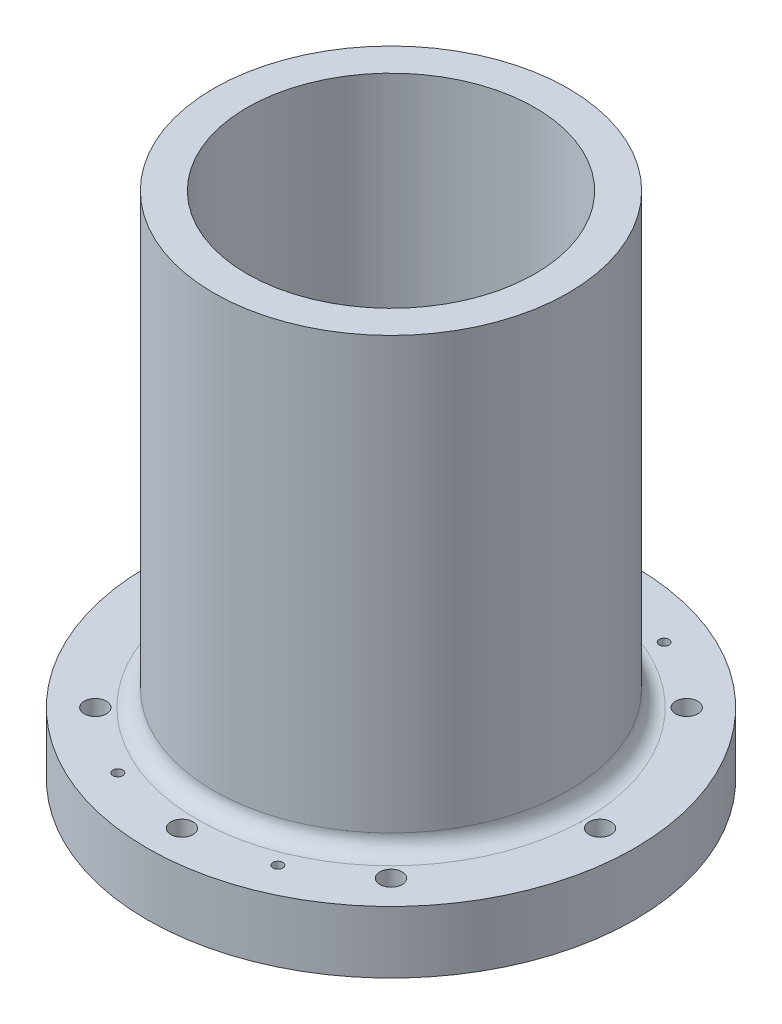
from build123d import *

# Parameters (mm, degrees)
SKETCH2_R               = 50.8
SKETCH2_R_2             = 41.275
BASE_CYLINDER_DEPTH     = 292.1
SKETCH3_R               = 69.85
SKETCH3_R_2             = 41.275
AFT_FLANGE_DEPTH        = 17.78
FORWARD_START           = -17.78
SKETCH4_R               = 69.85
SKETCH4_R_2             = 41.275
FORWARD_FLANGE_DEPTH    = 17.78
SKETCH6_R               = 50.0761
SKETCH6_R_2             = 47.0027
O_RING_SLOT_1_DEPTH     = 1.9812
O_RING_START            = -1.9812
SKETCH7_R               = 50.0761
SKETCH7_R_2             = 47.0027
O_RING_SLOT_2_DEPTH     = 1.9812
CUT_EXTRUDE4_DEPTH      = 309.351187771
CUT_EXTRUDE4_DEPTH_BACK = 309.351187771
SKETCH8_R               = 3.175
FILLET1_R               = 4.7625
SKETCH9_R               = 3.175
CUT_EXTRUDE5_DEPTH      = 7.62
CUT_EXTRUDE6_START      = -7.62
SKETCH10_R              = 3.175
CUT_EXTRUDE6_DEPTH      = 7.62
CUT_EXTRUDE7_REACH      = 303.143
SKETCH11_R              = 1.4097
CUT_EXTRUDE8_REACH      = 303.143
SKETCH12_R              = 1.4097
SKETCH13_R              = 2.3114
CUT_EXTRUDE10_DEPTH     = 6.35
CUT_EXTRUDE11_START     = -6.35
SKETCH14_R              = 2.3114
CUT_EXTRUDE11_DEPTH     = 6.35
CUT_EXTRUDE13_START     = -146.05
SKETCH18_R              = 69.85
CUT_EXTRUDE13_DEPTH     = 146.05


with BuildPart() as part:
    # Sketch2 → Base Cylinder (new body)
    with BuildSketch(Plane(origin=(0, 0, 0), x_dir=(1, 0, 0), z_dir=(0, 1, 0))):
        Circle(SKETCH2_R)
        Circle(SKETCH2_R_2, mode=Mode.SUBTRACT)
    extrude(amount=BASE_CYLINDER_DEPTH)

    # Sketch3 → Aft Flange (add)
    with BuildSketch(Plane.XZ):
        Circle(SKETCH3_R)
        Circle(SKETCH3_R_2, mode=Mode.SUBTRACT)
    extrude(amount=-AFT_FLANGE_DEPTH)

    # Sketch4 → Forward Flange (add)
    with BuildSketch(Plane(origin=(0, 292.1, 0), x_dir=(1, 0, 0), z_dir=(0, 1, 0)).offset(FORWARD_START)):
        Circle(SKETCH4_R)
        Circle(SKETCH4_R_2, mode=Mode.SUBTRACT)
    extrude(amount=FORWARD_FLANGE_DEPTH)

    # Sketch6 → O-Ring Slot 1 (cut)
    with BuildSketch(Plane.XZ):
        Circle(SKETCH6_R)
        Circle(SKETCH6_R_2, mode=Mode.SUBTRACT)
    extrude(amount=-O_RING_SLOT_1_DEPTH, mode=Mode.SUBTRACT)

    # Sketch7 → O-Ring Slot 2 (cut)
    with BuildSketch(Plane(origin=(0, 292.1, 0), x_dir=(1, 0, 0), z_dir=(0, 1, 0)).offset(O_RING_START)):
        Circle(SKETCH7_R)
        Circle(SKETCH7_R_2, mode=Mode.SUBTRACT)
    extrude(amount=O_RING_SLOT_2_DEPTH, mode=Mode.SUBTRACT)

    # Sketch8 → Cut-Extrude4 (cut, two sides: drawn at the far end of the back side and taken through both)
    with BuildSketch(Plane.XZ.offset(-CUT_EXTRUDE4_DEPTH_BACK)):
        with Locations((-59.9186, 0)):
            Circle(SKETCH8_R)
        with Locations((-42.368848379, 42.368848379)):
            Circle(SKETCH8_R)
        with Locations((0, 59.9186)):
            Circle(SKETCH8_R)
        with Locations((42.368848379, 42.368848379)):
            Circle(SKETCH8_R)
        with Locations((59.9186, 0)):
            Circle(SKETCH8_R)
        with Locations((42.368848379, -42.368848379)):
            Circle(SKETCH8_R)
        with Locations((0, -59.9186)):
            Circle(SKETCH8_R)
        with Locations((-42.368848379, -42.368848379)):
            Circle(SKETCH8_R)
    extrude(amount=CUT_EXTRUDE4_DEPTH + CUT_EXTRUDE4_DEPTH_BACK, mode=Mode.SUBTRACT)

    # Fillet1
    fillet1_edges = [part.edges().sort_by_distance(p)[0] for p in [
        (-50.8, 17.78, 0),
        (-50.8, 274.32, 0),
    ]]
    fillet(fillet1_edges, radius=FILLET1_R)

    # Sketch9 → Cut-Extrude5 (cut)
    with BuildSketch(Plane(origin=(0, 292.1, 0), x_dir=(1, 0, 0), z_dir=(0, 1, 0))):
        with Locations((-22.929855511, 55.357568157)):
            Circle(SKETCH9_R)
        with Locations((22.929855511, -55.357568157)):
            Circle(SKETCH9_R)
        with Locations((22.929855511, 55.357568157)):
            Circle(SKETCH9_R)
        with Locations((-22.929855511, -55.357568157)):
            Circle(SKETCH9_R)
    extrude(amount=-CUT_EXTRUDE5_DEPTH, mode=Mode.SUBTRACT)

    # Sketch10 → Cut-Extrude6 (cut)
    with BuildSketch(Plane.XZ.offset(CUT_EXTRUDE6_START)):
        with Locations((-22.929855511, 55.357568157)):
            Circle(SKETCH10_R)
        with Locations((22.929855511, -55.357568157)):
            Circle(SKETCH10_R)
        with Locations((22.929855511, 55.357568157)):
            Circle(SKETCH10_R)
        with Locations((-22.929855511, -55.357568157)):
            Circle(SKETCH10_R)
    extrude(amount=CUT_EXTRUDE6_DEPTH, mode=Mode.SUBTRACT)

    # Sketch11 → Cut-Extrude7 (cut, up to next)
    with BuildSketch(Plane(origin=(0, 284.48, 0), x_dir=(1, 0, 0), z_dir=(0, 1, 0)), mode=Mode.PRIVATE) as cut_extrude7_sk1:
        with Locations((-22.929855511, 55.357568157)):
            Circle(SKETCH11_R)
    cut_extrude7_tool1 = extrude(cut_extrude7_sk1.sketch, amount=-CUT_EXTRUDE7_REACH, mode=Mode.PRIVATE) & part.part
    # Sketch11 → Cut-Extrude7 (cut, up to next)
    with BuildSketch(Plane(origin=(0, 284.48, 0), x_dir=(1, 0, 0), z_dir=(0, 1, 0)), mode=Mode.PRIVATE) as cut_extrude7_sk2:
        with Locations((22.929855511, 55.357568157)):
            Circle(SKETCH11_R)
    cut_extrude7_tool2 = extrude(cut_extrude7_sk2.sketch, amount=-CUT_EXTRUDE7_REACH, mode=Mode.PRIVATE) & part.part
    # Sketch11 → Cut-Extrude7 (cut, up to next)
    with BuildSketch(Plane(origin=(0, 284.48, 0), x_dir=(1, 0, 0), z_dir=(0, 1, 0)), mode=Mode.PRIVATE) as cut_extrude7_sk3:
        with Locations((-22.929855511, -55.357568157)):
            Circle(SKETCH11_R)
    cut_extrude7_tool3 = extrude(cut_extrude7_sk3.sketch, amount=-CUT_EXTRUDE7_REACH, mode=Mode.PRIVATE) & part.part
    # Sketch11 → Cut-Extrude7 (cut, up to next)
    with BuildSketch(Plane(origin=(0, 284.48, 0), x_dir=(1, 0, 0), z_dir=(0, 1, 0)), mode=Mode.PRIVATE) as cut_extrude7_sk4:
        with Locations((22.929855511, -55.357568157)):
            Circle(SKETCH11_R)
    cut_extrude7_tool4 = extrude(cut_extrude7_sk4.sketch, amount=-CUT_EXTRUDE7_REACH, mode=Mode.PRIVATE) & part.part
    add(cut_extrude7_tool1.solids().sort_by_distance((-22.929856, 284.48, -55.357568))[0], mode=Mode.SUBTRACT)
    add(cut_extrude7_tool2.solids().sort_by_distance((22.929856, 284.48, -55.357568))[0], mode=Mode.SUBTRACT)
    add(cut_extrude7_tool3.solids().sort_by_distance((-22.929856, 284.48, 55.357568))[0], mode=Mode.SUBTRACT)
    add(cut_extrude7_tool4.solids().sort_by_distance((22.929856, 284.48, 55.357568))[0], mode=Mode.SUBTRACT)

    # Sketch12 → Cut-Extrude8 (cut, up to next)
    with BuildSketch(Plane.XZ.offset(-7.62), mode=Mode.PRIVATE) as cut_extrude8_sk1:
        with Locations((-22.929855511, 55.357568157)):
            Circle(SKETCH12_R)
    cut_extrude8_tool1 = extrude(cut_extrude8_sk1.sketch, amount=-CUT_EXTRUDE8_REACH, mode=Mode.PRIVATE) & part.part
    # Sketch12 → Cut-Extrude8 (cut, up to next)
    with BuildSketch(Plane.XZ.offset(-7.62), mode=Mode.PRIVATE) as cut_extrude8_sk2:
        with Locations((22.929855511, 55.357568157)):
            Circle(SKETCH12_R)
    cut_extrude8_tool2 = extrude(cut_extrude8_sk2.sketch, amount=-CUT_EXTRUDE8_REACH, mode=Mode.PRIVATE) & part.part
    # Sketch12 → Cut-Extrude8 (cut, up to next)
    with BuildSketch(Plane.XZ.offset(-7.62), mode=Mode.PRIVATE) as cut_extrude8_sk3:
        with Locations((-22.929855511, -55.357568157)):
            Circle(SKETCH12_R)
    cut_extrude8_tool3 = extrude(cut_extrude8_sk3.sketch, amount=-CUT_EXTRUDE8_REACH, mode=Mode.PRIVATE) & part.part
    # Sketch12 → Cut-Extrude8 (cut, up to next)
    with BuildSketch(Plane.XZ.offset(-7.62), mode=Mode.PRIVATE) as cut_extrude8_sk4:
        with Locations((22.929855511, -55.357568157)):
            Circle(SKETCH12_R)
    cut_extrude8_tool4 = extrude(cut_extrude8_sk4.sketch, amount=-CUT_EXTRUDE8_REACH, mode=Mode.PRIVATE) & part.part
    add(cut_extrude8_tool1.solids().sort_by_distance((-22.929856, 7.62, 55.357568))[0], mode=Mode.SUBTRACT)
    add(cut_extrude8_tool2.solids().sort_by_distance((22.929856, 7.62, 55.357568))[0], mode=Mode.SUBTRACT)
    add(cut_extrude8_tool3.solids().sort_by_distance((-22.929856, 7.62, -55.357568))[0], mode=Mode.SUBTRACT)
    add(cut_extrude8_tool4.solids().sort_by_distance((22.929856, 7.62, -55.357568))[0], mode=Mode.SUBTRACT)

    # Sketch13 → Cut-Extrude10 (cut)
    with BuildSketch(Plane(origin=(-69.85, 0, 0), x_dir=(0, 0, -1), z_dir=(1, 0, 0))):
        with Locations((0, 283.21)):
            Circle(SKETCH13_R)
    extrude(amount=CUT_EXTRUDE10_DEPTH, mode=Mode.SUBTRACT)

    # Sketch14 → Cut-Extrude11 (cut)
    with BuildSketch(Plane(origin=(69.85, 0, 0), x_dir=(0, 0, -1), z_dir=(1, 0, 0)).offset(CUT_EXTRUDE11_START)):
        with Locations((0, 283.21)):
            Circle(SKETCH14_R)
    extrude(amount=CUT_EXTRUDE11_DEPTH, mode=Mode.SUBTRACT)

    # Sketch18 → Cut-Extrude13 (cut)
    with BuildSketch(Plane(origin=(0, 292.1, 0), x_dir=(1, 0, 0), z_dir=(0, 1, 0)).offset(CUT_EXTRUDE13_START)):
        Circle(SKETCH18_R)
    extrude(amount=CUT_EXTRUDE13_DEPTH, mode=Mode.SUBTRACT)


solid = part.part
